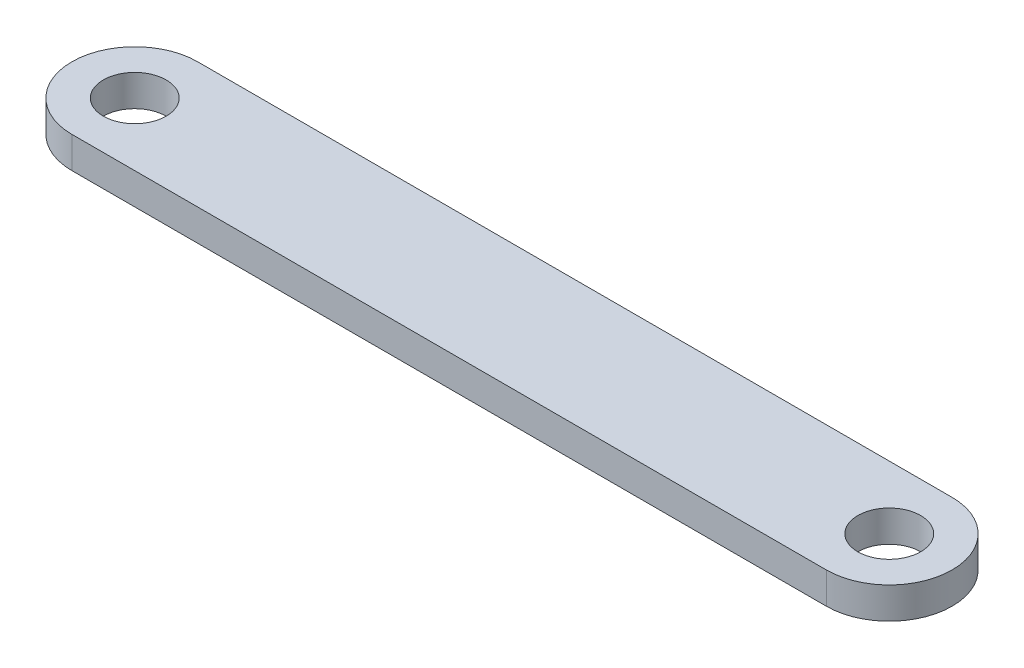
from build123d import *

# Parameters (mm, degrees)
SKETCH2_R           = 5
BOSS_EXTRUDE1_DEPTH = 5


with BuildPart() as part:
    # Sketch2 → Boss-Extrude1 (new body)
    with BuildSketch(Plane(origin=(0, 0, 0), x_dir=(1, 0, 0), z_dir=(0, 1, 0))):
        with BuildLine():
            Line((-60, 10), (60, 10))
            ThreePointArc((60, 10), (70, 0), (60, -10))
            Line((60, -10), (-60, -10))
            ThreePointArc((-60, -10), (-70, 0), (-60, 10))
        make_face()
        with Locations((-60, 0)):
            Circle(SKETCH2_R, mode=Mode.SUBTRACT)
        with Locations((60, 0)):
            Circle(SKETCH2_R, mode=Mode.SUBTRACT)
    extrude(amount=BOSS_EXTRUDE1_DEPTH)


solid = part.part
